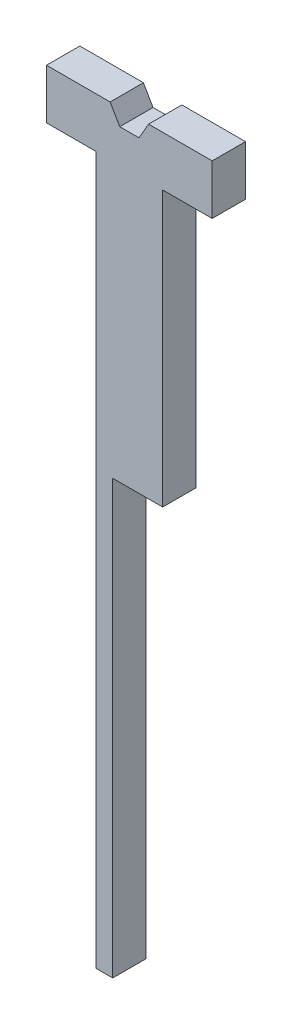
from build123d import *

# Parameters (mm, degrees)
SKETCH1_W             = 20
SKETCH1_H             = 197.5
SKETCH1_H_2           = 15
SKETCH1_W_2           = 14.875
BOSS_EXTRUDE1_DEPTH   = 10
IZIM1_W               = 10
IZIM1_H               = 130
KES_EKSTR_ZYON1_DEPTH = 15


with BuildPart() as part:
    # Sketch1 → Boss-Extrude1 (new body)
    with BuildSketch(Plane.XY):
        with Locations((0, -121.25)):
            Rectangle(SKETCH1_W, SKETCH1_H)
        with Locations((0, -15)):
            Rectangle(SKETCH1_W, SKETCH1_H_2)
        Polygon((-10, 7.5), (-10, -7.5), (10, -7.5), (10, 7.5), (5.773502692, 7.5), (2.886751346, 2.5), (-2.886751346, 2.5), (-5.773502692, 7.5), align=None)
        with Locations((-17.4375, 0)):
            Rectangle(SKETCH1_W_2, SKETCH1_H_2)
        with Locations((17.4375, 0)):
            Rectangle(SKETCH1_W_2, SKETCH1_H_2)
    extrude(amount=BOSS_EXTRUDE1_DEPTH)

    # Çizim1 → Kes-Ekstrüzyon1 (cut)
    with BuildSketch(Plane(origin=(10, 0, 0), x_dir=(0, 0, -1), z_dir=(1, 0, 0))):
        with Locations((-5, -155)):
            Rectangle(IZIM1_W, IZIM1_H)
    extrude(amount=-KES_EKSTR_ZYON1_DEPTH, mode=Mode.SUBTRACT)


solid = part.part
